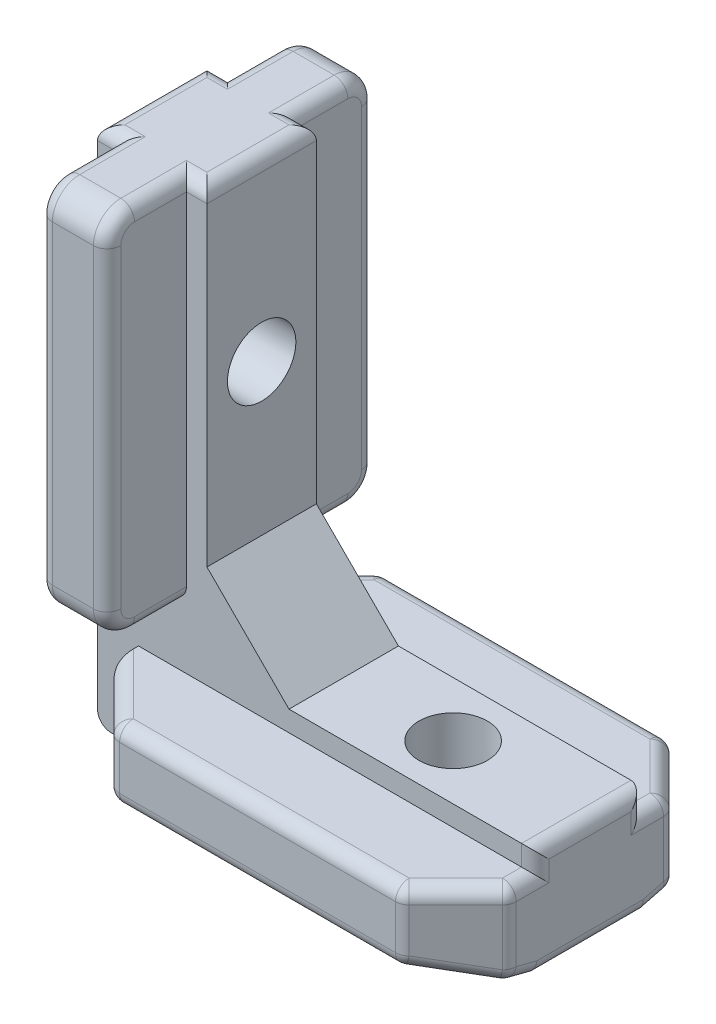
from build123d import *

# Parameters (mm, degrees)
BOSS_EXTRUDE1_DEPTH = 4
BOSS_EXTRUDE2_DEPTH = 29
CHAMFER1_SIZE       = 4
CHAMFER2_SIZE       = 6
CUT_EXTRUDE1_REACH  = 40
SKETCH3_R           = 2.5
CUT_EXTRUDE2_REACH  = 34
SKETCH4_R           = 2.5
SKETCH5_W           = 5
SKETCH5_H           = 5.8
BOSS_EXTRUDE3_DEPTH = 27
FILLET1_R           = 2
FILLET2_R           = 1


with BuildPart() as part:
    # Sketch1 → Boss-Extrude1 (new body, symmetric)
    with BuildSketch(Plane.XY):
        Polygon((0, 0), (0, 38), (8, 38), (8, 8), (32, 8), (32, 0), align=None)
    extrude(amount=BOSS_EXTRUDE1_DEPTH, both=True)

    # Sketch2 → Boss-Extrude2 (add)
    with BuildSketch(Plane(origin=(32, 0, 0), x_dir=(0, 0, -1), z_dir=(1, 0, 0))):
        Polygon((-4, 6.5), (-9.8, 6.5), (-9.8, 1.5), (-4, 0), align=None)
        Polygon((4, 0), (4, 6.5), (9.8, 6.5), (9.8, 1.5), align=None)
    extrude(amount=-BOSS_EXTRUDE2_DEPTH)

    # Chamfer1
    chamfer1_edges = [part.edges().sort_by_distance(p)[0] for p in [
        (3, 4, 9.8),
        (32, 4, 9.8),
        (3, 4, -9.8),
        (32, 4, -9.8),
    ]]
    chamfer(chamfer1_edges, length=CHAMFER1_SIZE)

    # Chamfer2
    chamfer2_edges = [part.edges().sort_by_distance(p)[0] for p in [
        (8, 8, 0),
    ]]
    chamfer(chamfer2_edges, length=CHAMFER2_SIZE)

    # Sketch3 → Cut-Extrude1 (cut, up to next)
    with BuildSketch(Plane.XZ, mode=Mode.PRIVATE) as cut_extrude1_sk1:
        with Locations((22, 0)):
            Circle(SKETCH3_R)
    cut_extrude1_tool1 = extrude(cut_extrude1_sk1.sketch, amount=-CUT_EXTRUDE1_REACH, mode=Mode.PRIVATE) & part.part
    add(cut_extrude1_tool1.solids().sort_by_distance((22, 0, 0))[0], mode=Mode.SUBTRACT)

    # Sketch4 → Cut-Extrude2 (cut, up to next)
    with BuildSketch(Plane.ZY, mode=Mode.PRIVATE) as cut_extrude2_sk1:
        with Locations((0, 25)):
            Circle(SKETCH4_R)
    cut_extrude2_tool1 = extrude(cut_extrude2_sk1.sketch, amount=-CUT_EXTRUDE2_REACH, mode=Mode.PRIVATE) & part.part
    add(cut_extrude2_tool1.solids().sort_by_distance((0, 25, 0))[0], mode=Mode.SUBTRACT)

    # Sketch5 → Boss-Extrude3 (add)
    with BuildSketch(Plane(origin=(0, 38, 0), x_dir=(1, 0, 0), z_dir=(0, 1, 0))):
        with Locations((4, 6.9)):
            Rectangle(SKETCH5_W, SKETCH5_H)
        with Locations((4, -6.9)):
            Rectangle(SKETCH5_W, SKETCH5_H)
    extrude(amount=-BOSS_EXTRUDE3_DEPTH)

    # Fillet1
    fillet1_edges = [part.edges().sort_by_distance(p)[0] for p in [
        (4, 38, 9.8),
        (4, 11, -9.8),
        (4, 38, -9.8),
        (4, 11, 9.8),
    ]]
    fillet(fillet1_edges, radius=FILLET1_R)

    # Fillet2
    fillet2_edges = [part.edges().sort_by_distance(p)[0] for p in [
        (1.5, 38, 5.9),
        (6.5, 24.5, -9.8),
        (0, 0, 0),
        (1.5, 24.5, -9.8),
        (0, 38, 0),
        (1.5, 38, -5.9),
        (8, 38, 0),
        (1.5, 11, -5.9),
        (1.5, 37.414213562, -9.214213562),
        (1.5, 11.585786438, -9.214213562),
        (32, 8, 0),
        (6.5, 37.414213562, -9.214213562),
        (6.5, 11.585786438, -9.214213562),
        (32, 0, 0),
        (1.5, 24.5, 9.8),
        (6.5, 24.5, 9.8),
        (6.5, 38, 5.9),
        (6.5, 11, 5.9),
        (6.5, 37.414213562, 9.214213562),
        (6.5, 11.585786438, 9.214213562),
        (1.5, 37.414213562, 9.214213562),
        (1.5, 11.585786438, 9.214213562),
        (32, 7.25, 4),
        (7.25, 38, 4),
        (32, 6.5, 4.9),
        (32, 7.25, -4),
        (32, 0.232758621, -4.9),
        (17.5, 1.5, -9.8),
        (17.5, 6.5, -9.8),
        (28, 4, -9.8),
        (7, 4, -9.8),
        (32, 6.5, -4.9),
        (30, 6.5, -7.8),
        (5, 6.5, -7.8),
        (3, 3.482758621, -5.8),
        (30, 0.982758621, -7.8),
        (5, 0.982758621, -7.8),
        (17.5, 6.5, 9.8),
        (17.5, 1.5, 9.8),
        (28, 4, 9.8),
        (7, 4, 9.8),
        (32, 0.232758621, 4.9),
        (30, 0.982758621, 7.8),
        (5, 0.982758621, 7.8),
        (3, 3.482758621, 5.8),
        (30, 6.5, 7.8),
        (5, 6.5, 7.8),
        (32, 3.482758621, 5.8),
        (32, 3.482758621, -5.8),
        (7.25, 38, -4),
        (0.75, 38, -4),
        (6.5, 11, -5.9),
        (6.5, 38, -5.9),
        (0.75, 38, 4),
        (1.5, 11, 5.9),
    ]]
    fillet(fillet2_edges, radius=FILLET2_R)


solid = part.part
